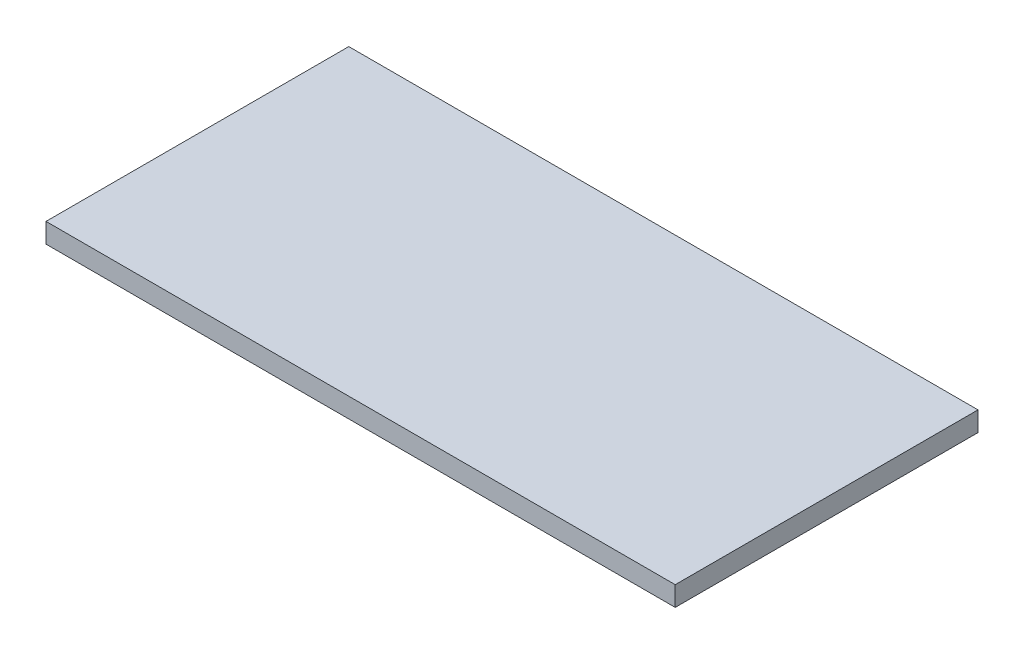
from build123d import *

# Parameters (mm, degrees)
SKETCH1_W           = 202.692
SKETCH1_H           = 97.536
BOSS_EXTRUDE1_DEPTH = 6.35


with BuildPart() as part:
    # Sketch1 → Boss-Extrude1 (new body)
    with BuildSketch(Plane(origin=(0, 0, 0), x_dir=(1, 0, 0), z_dir=(0, 1, 0))):
        with Locations((101.346, 48.768)):
            Rectangle(SKETCH1_W, SKETCH1_H)
    extrude(amount=BOSS_EXTRUDE1_DEPTH)


solid = part.part
